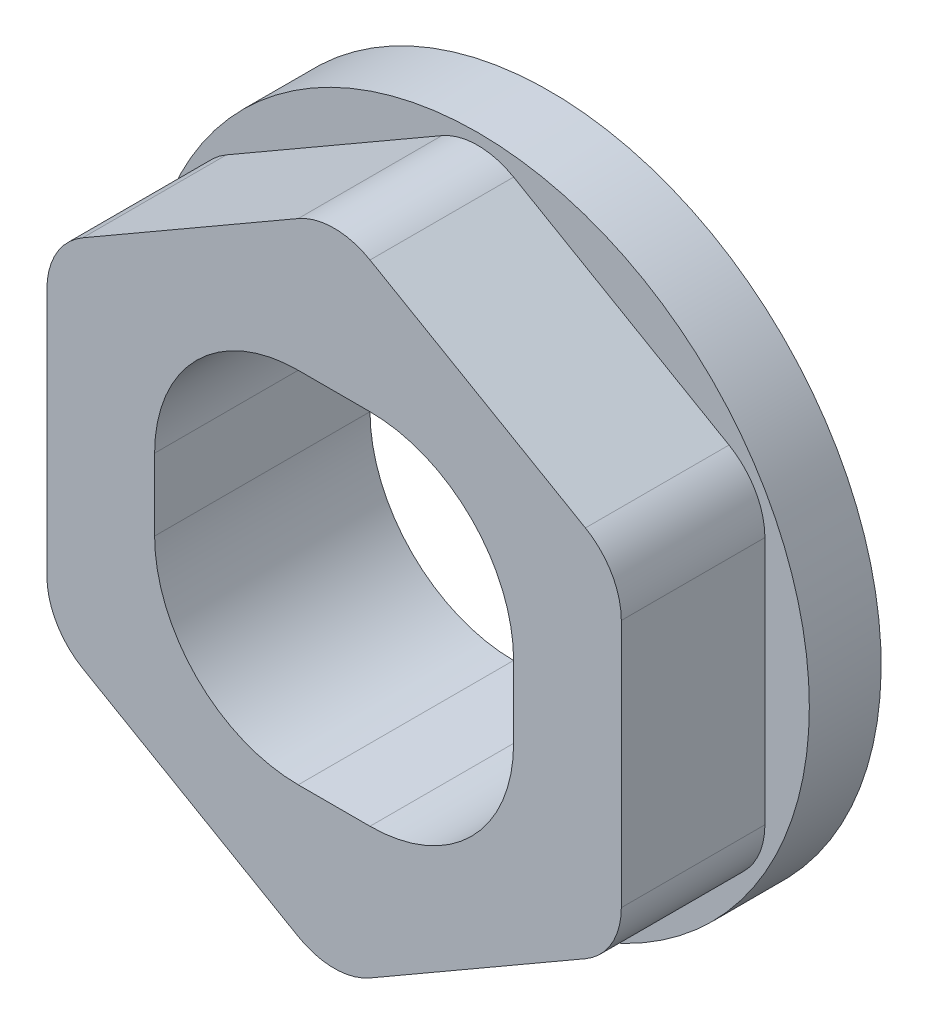
from build123d import *

# Parameters (mm, degrees)
BOSS_EXTRUDE1_DEPTH = 10
SKETCH2_R           = 23.094010768
BOSS_EXTRUDE2_DEPTH = 5
FILLET1_R           = 5


with BuildPart() as part:
    # Sketch1 → Boss-Extrude1 (new body)
    with BuildSketch(Plane.XY):
        Polygon((20, -11.547005384), (20, 11.547005384), (0, 23.094010768), (-20, 11.547005384), (-20, -11.547005384), (0, -23.094010768), align=None)
        with BuildLine():
            Line((2.5, -12.5), (-2.5, -12.5))
            ThreePointArc((-2.5, -12.5), (-9.571067812, -9.571067812), (-12.5, -2.5))
            Line((-12.5, -2.5), (-12.5, 2.5))
            ThreePointArc((-12.5, 2.5), (-9.571067812, 9.571067812), (-2.5, 12.5))
            Line((-2.5, 12.5), (2.5, 12.5))
            ThreePointArc((2.5, 12.5), (9.571067812, 9.571067812), (12.5, 2.5))
            Line((12.5, 2.5), (12.5, -2.5))
            ThreePointArc((12.5, -2.5), (9.571067812, -9.571067812), (2.5, -12.5))
        make_face(mode=Mode.SUBTRACT)
    extrude(amount=BOSS_EXTRUDE1_DEPTH)

    # Sketch2 → Boss-Extrude2 (add)
    with BuildSketch(Plane(origin=(0, 0, 0), x_dir=(-1, 0, 0), z_dir=(0, 0, -1))):
        Circle(SKETCH2_R)
        with BuildLine():
            Line((-2.5, 12.5), (2.5, 12.5))
            ThreePointArc((2.5, 12.5), (9.571067812, 9.571067812), (12.5, 2.5))
            Line((12.5, 2.5), (12.5, -2.5))
            ThreePointArc((12.5, -2.5), (9.571067812, -9.571067812), (2.5, -12.5))
            Line((2.5, -12.5), (-2.5, -12.5))
            ThreePointArc((-2.5, -12.5), (-9.571067812, -9.571067812), (-12.5, -2.5))
            Line((-12.5, -2.5), (-12.5, 2.5))
            ThreePointArc((-12.5, 2.5), (-9.571067812, 9.571067812), (-2.5, 12.5))
        make_face(mode=Mode.SUBTRACT)
    extrude(amount=BOSS_EXTRUDE2_DEPTH)

    # Fillet1
    fillet1_edges = [part.edges().sort_by_distance(p)[0] for p in [
        (20, -11.547005384, 5),
        (0, -23.094010768, 5),
        (-20, -11.547005384, 5),
        (-20, 11.547005384, 5),
        (0, 23.094010768, 5),
        (20, 11.547005384, 5),
    ]]
    fillet(fillet1_edges, radius=FILLET1_R)


solid = part.part
